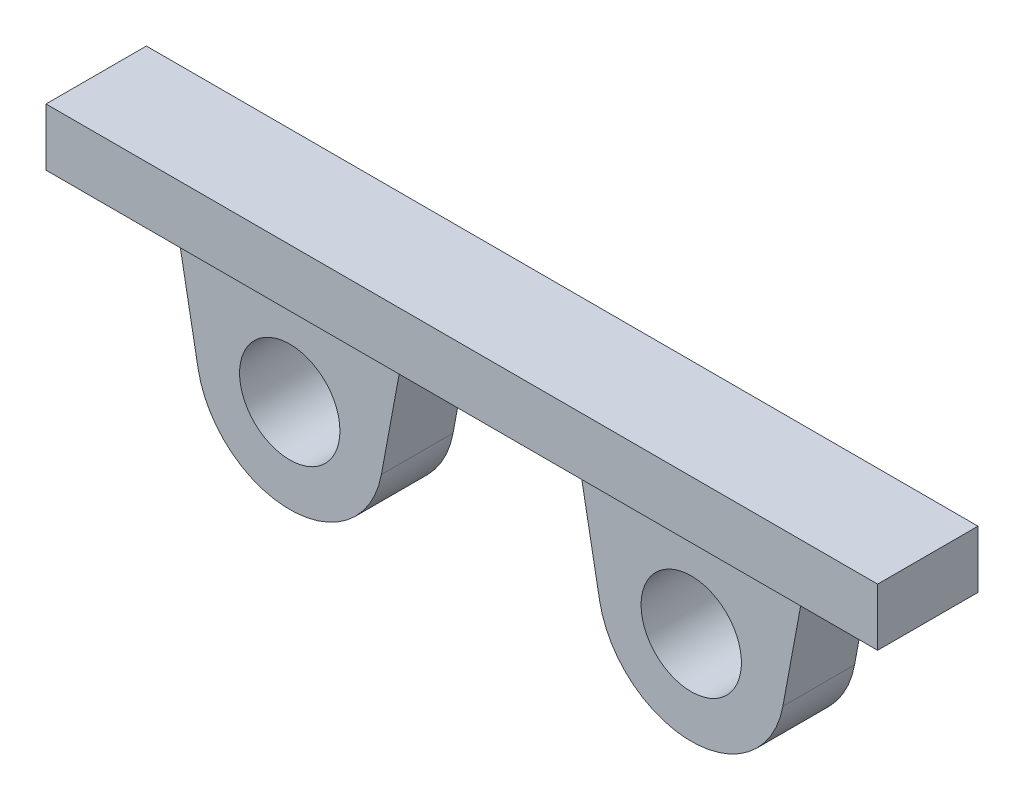
from build123d import *

# Parameters (mm, degrees)
SKETCH_1_R      = 3.5
EXTRUDE_1_DEPTH = 5
SKETCH_2_W      = 58
SKETCH_2_H      = 2
EXTRUDE_2_DEPTH = 4


with BuildPart() as part:
    # 草图1 → 凸台-拉伸1 (new body)
    with BuildSketch(Plane.XY):
        with BuildLine():
            Line((-7.608745595, -1.184004699), (-6, 7.5))
            Line((-6, 7.5), (6, 7.5))
            Line((6, 7.5), (7.608745595, -1.184004699))
            ThreePointArc((7.608745595, -1.184004699), (14, -6.5), (20.391254405, -1.184004699))
            Line((20.391254405, -1.184004699), (22, 7.5))
            Line((22, 7.5), (29, 7.5))
            Line((29, 7.5), (29, 11.5))
            Line((29, 11.5), (-29, 11.5))
            Line((-29, 11.5), (-29, 7.5))
            Line((-29, 7.5), (-22, 7.5))
            Line((-22, 7.5), (-20.391254405, -1.184004699))
            ThreePointArc((-20.391254405, -1.184004699), (-14, -6.5), (-7.608745595, -1.184004699))
        make_face()
        with Locations((-14, 0)):
            Circle(SKETCH_1_R, mode=Mode.SUBTRACT)
        with Locations((14, 0)):
            Circle(SKETCH_1_R, mode=Mode.SUBTRACT)
    extrude(amount=EXTRUDE_1_DEPTH)

    # 草图2 → 凸台-拉伸2 (add)
    with BuildSketch(Plane.XZ.offset(-7.5)):
        with Locations((0, 6)):
            Rectangle(SKETCH_2_W, SKETCH_2_H)
    extrude(amount=-EXTRUDE_2_DEPTH)


solid = part.part
